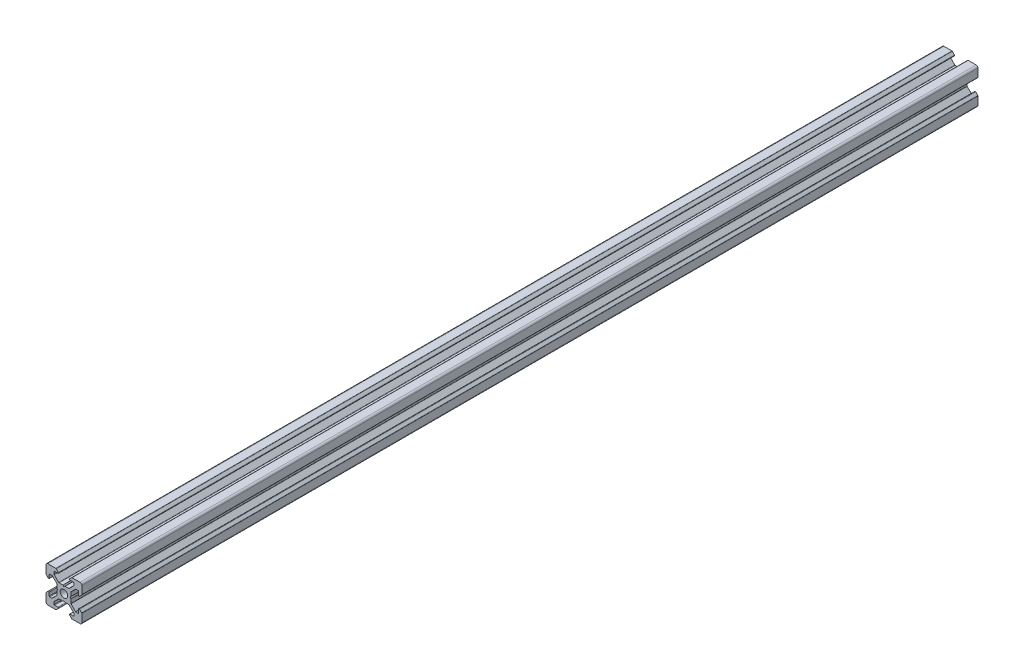
from build123d import *

# Parameters (mm, degrees)
SKETCH_1_R      = 2.1
EXTRUDE_1_DEPTH = 500
FILLET_1_R      = 1
FILLET_2_R      = 0.3


with BuildPart() as part:
    # Эскиз1 → Бобышка-Вытянуть1 (new body)
    with BuildSketch(Plane.XY):
        Polygon((-10, 10), (-4.4, 10), (-2.6, 8.2), (-5.499339828, 8.2), (-5.499339828, 6.56), (-2.84, 3.900660172), (-0.5, 3.900660172), (0, 3.400660172), (0.5, 3.900660172), (2.84, 3.900660172), (5.499339828, 6.56), (5.499339828, 8.2), (2.6, 8.2), (4.4, 10), (10, 10), (10, 4.4), (8.2, 2.6), (8.2, 5.499339828), (6.56, 5.499339828), (3.900660172, 2.84), (3.900660172, 0.5), (3.400660172, 0), (3.900660172, -0.5), (3.900660172, -2.84), (6.56, -5.499339828), (8.2, -5.499339828), (8.2, -2.6), (10, -4.4), (10, -10), (4.4, -10), (2.6, -8.2), (5.499339828, -8.2), (5.499339828, -6.56), (2.84, -3.900660172), (0.5, -3.900660172), (0, -3.400660172), (-0.5, -3.900660172), (-2.84, -3.900660172), (-5.499339828, -6.56), (-5.499339828, -8.2), (-2.6, -8.2), (-4.4, -10), (-10, -10), (-10, -4.4), (-8.2, -2.6), (-8.2, -5.499339828), (-6.56, -5.499339828), (-3.900660172, -2.84), (-3.900660172, -0.5), (-3.400660172, 0), (-3.900660172, 0.5), (-3.900660172, 2.84), (-6.56, 5.499339828), (-8.2, 5.499339828), (-8.2, 2.6), (-10, 4.4), align=None)
        Circle(SKETCH_1_R, mode=Mode.SUBTRACT)
    extrude(amount=EXTRUDE_1_DEPTH)

    # Скругление1
    fillet_1_edges = [part.edges().sort_by_distance(p)[0] for p in [
        (-10, 10, 250),
        (10, 10, 250),
        (10, -10, 250),
        (-10, -10, 250),
    ]]
    fillet(fillet_1_edges, radius=FILLET_1_R)

    # Скругление2
    fillet_2_edges = [part.edges().sort_by_distance(p)[0] for p in [
        (-4.4, 10, 250),
        (-2.6, 8.2, 250),
        (-5.499339828, 8.2, 250),
        (-5.499339828, 6.56, 250),
        (-2.84, 3.900660172, 250),
        (-0.5, 3.900660172, 250),
        (0.5, 3.900660172, 250),
        (2.84, 3.900660172, 250),
        (5.499339828, 6.56, 250),
        (5.499339828, 8.2, 250),
        (2.6, 8.2, 250),
        (4.4, 10, 250),
        (10, 4.4, 250),
        (8.2, 2.6, 250),
        (8.2, 5.499339828, 250),
        (6.56, 5.499339828, 250),
        (3.900660172, 2.84, 250),
        (3.900660172, 0.5, 250),
        (3.900660172, -0.5, 250),
        (3.900660172, -2.84, 250),
        (6.56, -5.499339828, 250),
        (8.2, -5.499339828, 250),
        (8.2, -2.6, 250),
        (10, -4.4, 250),
        (4.4, -10, 250),
        (2.6, -8.2, 250),
        (5.499339828, -8.2, 250),
        (5.499339828, -6.56, 250),
        (2.84, -3.900660172, 250),
        (0.5, -3.900660172, 250),
        (-0.5, -3.900660172, 250),
        (-2.84, -3.900660172, 250),
        (-5.499339828, -6.56, 250),
        (-5.499339828, -8.2, 250),
        (-2.6, -8.2, 250),
        (-4.4, -10, 250),
        (-10, -4.4, 250),
        (-8.2, -2.6, 250),
        (-8.2, -5.499339828, 250),
        (-6.56, -5.499339828, 250),
        (-3.900660172, -2.84, 250),
        (-3.900660172, -0.5, 250),
        (-3.900660172, 0.5, 250),
        (-3.900660172, 2.84, 250),
        (-6.56, 5.499339828, 250),
        (-8.2, 5.499339828, 250),
        (-8.2, 2.6, 250),
    ]]
    fillet(fillet_2_edges, radius=FILLET_2_R)


solid = part.part
